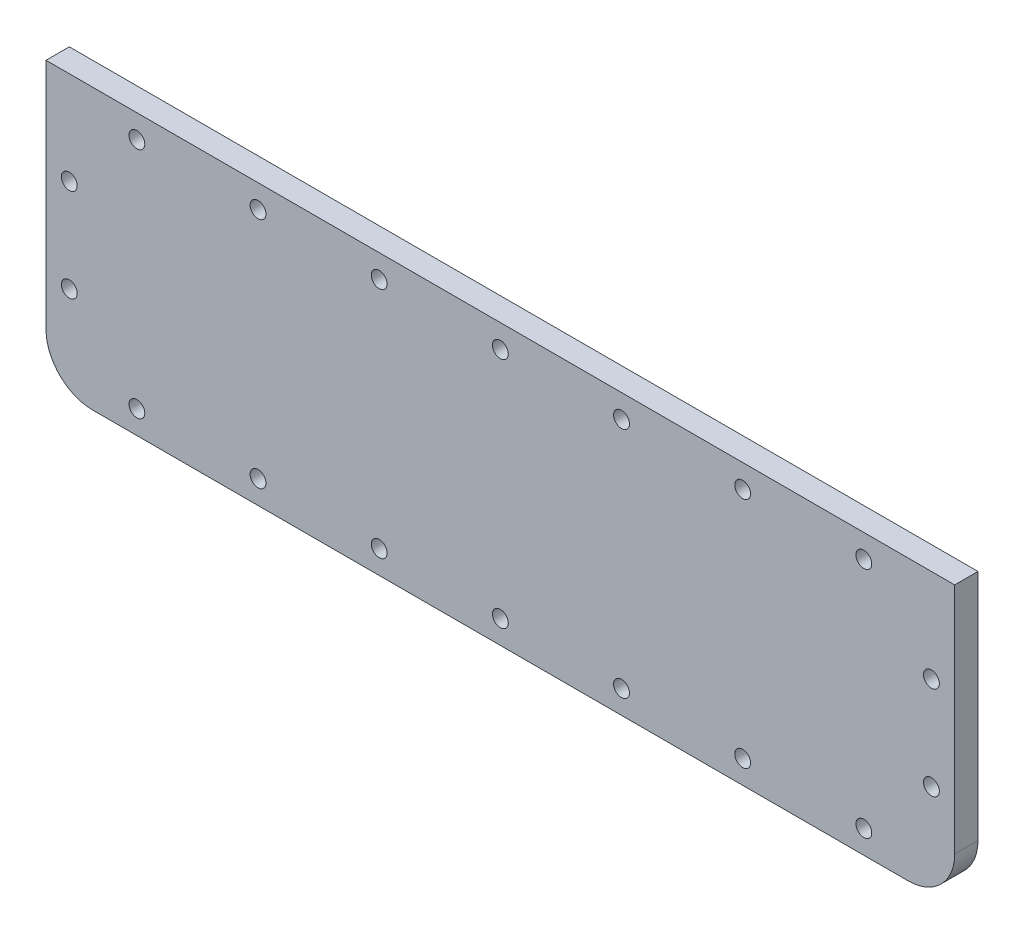
from build123d import *

# Parameters (mm, degrees)
SKETCH1_W           = 247.65
SKETCH1_H           = 76.2
SKETCH1_R           = 2.159
BOSS_EXTRUDE1_DEPTH = 6.35
FILLET1_R           = 12.7


with BuildPart() as part:
    # Sketch1 → Boss-Extrude1 (new body)
    with BuildSketch(Plane.XY):
        Rectangle(SKETCH1_W, SKETCH1_H)
        with Locations((-117.475, 12.7)):
            Circle(SKETCH1_R, mode=Mode.SUBTRACT)
        with Locations((-117.475, -12.7)):
            Circle(SKETCH1_R, mode=Mode.SUBTRACT)
        with Locations((-99.06, -31.75)):
            Circle(SKETCH1_R, mode=Mode.SUBTRACT)
        with Locations((-66.04, -31.75)):
            Circle(SKETCH1_R, mode=Mode.SUBTRACT)
        with Locations((-33.02, -31.75)):
            Circle(SKETCH1_R, mode=Mode.SUBTRACT)
        with Locations((0, -31.75)):
            Circle(SKETCH1_R, mode=Mode.SUBTRACT)
        with Locations((33.02, -31.75)):
            Circle(SKETCH1_R, mode=Mode.SUBTRACT)
        with Locations((66.04, -31.75)):
            Circle(SKETCH1_R, mode=Mode.SUBTRACT)
        with Locations((99.06, -31.75)):
            Circle(SKETCH1_R, mode=Mode.SUBTRACT)
        with Locations((117.475, -12.7)):
            Circle(SKETCH1_R, mode=Mode.SUBTRACT)
        with Locations((117.475, 12.7)):
            Circle(SKETCH1_R, mode=Mode.SUBTRACT)
        with Locations((99.06, 31.75)):
            Circle(SKETCH1_R, mode=Mode.SUBTRACT)
        with Locations((66.04, 31.75)):
            Circle(SKETCH1_R, mode=Mode.SUBTRACT)
        with Locations((33.02, 31.75)):
            Circle(SKETCH1_R, mode=Mode.SUBTRACT)
        with Locations((0, 31.75)):
            Circle(SKETCH1_R, mode=Mode.SUBTRACT)
        with Locations((-33.02, 31.75)):
            Circle(SKETCH1_R, mode=Mode.SUBTRACT)
        with Locations((-66.04, 31.75)):
            Circle(SKETCH1_R, mode=Mode.SUBTRACT)
        with Locations((-99.06, 31.75)):
            Circle(SKETCH1_R, mode=Mode.SUBTRACT)
    extrude(amount=BOSS_EXTRUDE1_DEPTH)

    # Fillet1
    fillet1_edges = [part.edges().sort_by_distance(p)[0] for p in [
        (123.825, -38.1, 3.175),
        (-123.825, -38.1, 3.175),
    ]]
    fillet(fillet1_edges, radius=FILLET1_R)


solid = part.part
